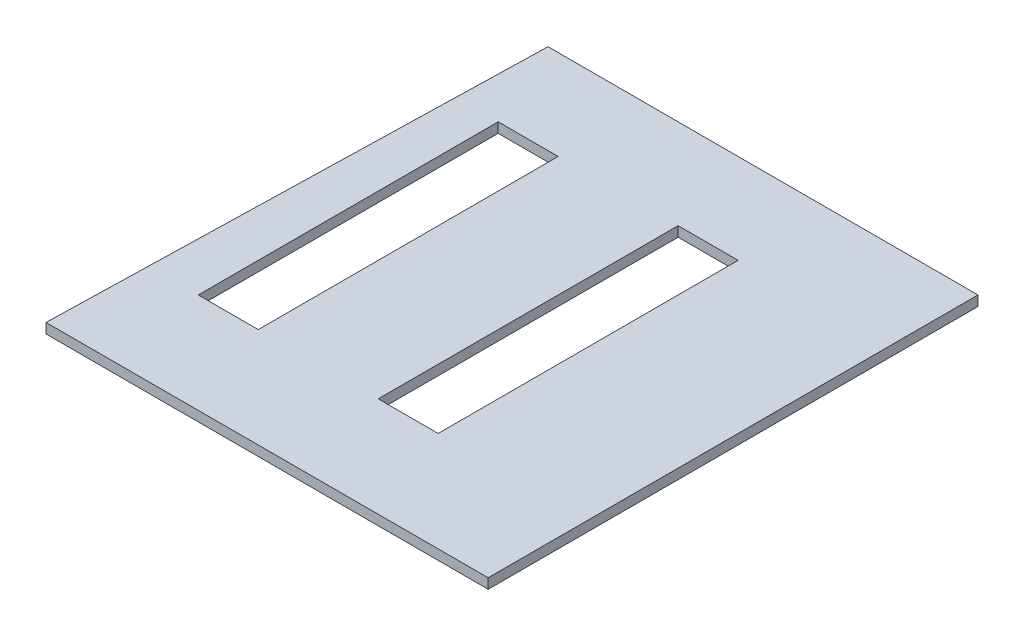
from build123d import *

# Parameters (mm, degrees)
BOSS_EXTRUDE1_DEPTH = 50.8
SKETCH2_W           = 304.8
SKETCH2_H           = 1524
CUT_EXTRUDE1_DEPTH  = 50.8


with BuildPart() as part:
    # Sketch1 → Boss-Extrude1 (new body)
    with BuildSketch(Plane(origin=(0, 0, 0), x_dir=(1, 0, 0), z_dir=(0, 1, 0))):
        Polygon((-1123.874350932, -1244.938243374), (-1061.898350932, 1244.261756626), (1123.263649068, 1244.261756626), (1123.263649068, -1244.938243374), align=None)
    extrude(amount=BOSS_EXTRUDE1_DEPTH)

    # Sketch2 → Cut-Extrude1 (cut)
    with BuildSketch(Plane(origin=(0, 50.8, 0), x_dir=(1, 0, 0), z_dir=(0, 1, 0))):
        with Locations((208.863649068, 25.061756626)):
            Rectangle(SKETCH2_W, SKETCH2_H)
        with Locations((-705.536350932, 25.061756626)):
            Rectangle(SKETCH2_W, SKETCH2_H)
    extrude(amount=-CUT_EXTRUDE1_DEPTH, mode=Mode.SUBTRACT)


solid = part.part
